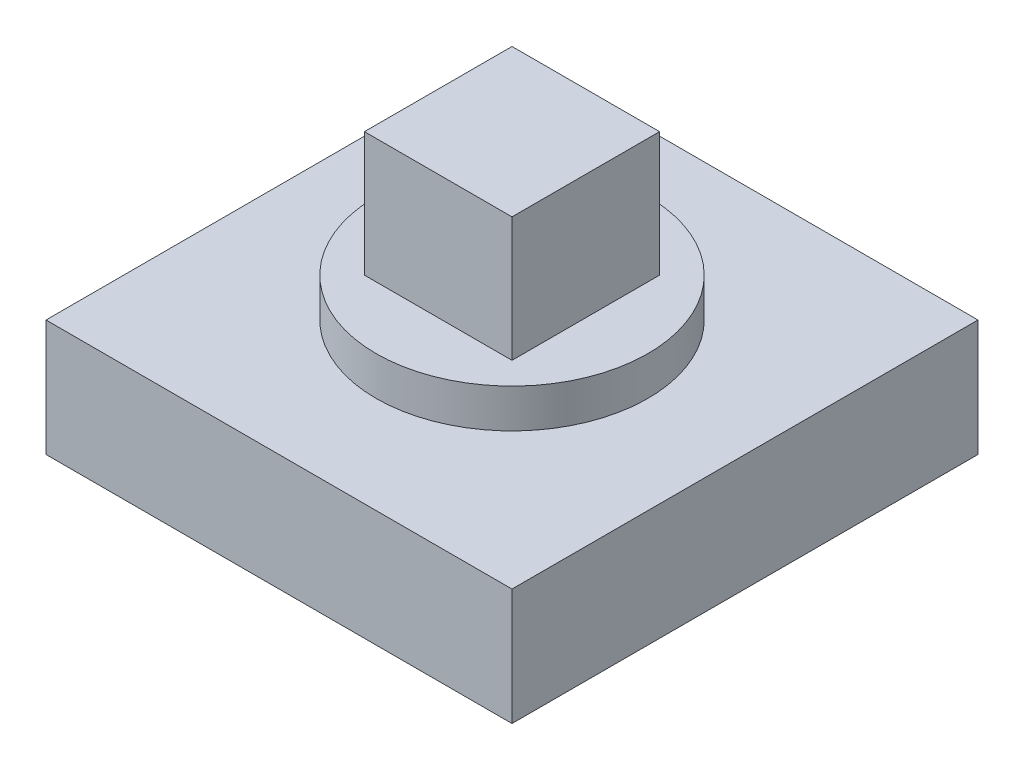
from build123d import *

# Parameters (mm, degrees)
SKETCH1_W           = 12
SKETCH1_H           = 12
BOSS_EXTRUDE1_DEPTH = 3
SKETCH3_R           = 3.5
BOSS_EXTRUDE2_DEPTH = 1
SKETCH4_W           = 3.8
SKETCH4_H           = 3.8
BOSS_EXTRUDE3_DEPTH = 3.2


with BuildPart() as part:
    # Sketch1 → Boss-Extrude1 (new body)
    with BuildSketch(Plane(origin=(0, 0, 0), x_dir=(1, 0, 0), z_dir=(0, 1, 0))):
        Rectangle(SKETCH1_W, SKETCH1_H)
    extrude(amount=BOSS_EXTRUDE1_DEPTH)

    # Sketch3 → Boss-Extrude2 (add)
    with BuildSketch(Plane(origin=(0, 3, 0), x_dir=(1, 0, 0), z_dir=(0, 1, 0))):
        Circle(SKETCH3_R)
    extrude(amount=BOSS_EXTRUDE2_DEPTH)

    # Sketch4 → Boss-Extrude3 (add)
    with BuildSketch(Plane(origin=(0, 4, 0), x_dir=(1, 0, 0), z_dir=(0, 1, 0))):
        Rectangle(SKETCH4_W, SKETCH4_H)
    extrude(amount=BOSS_EXTRUDE3_DEPTH)


solid = part.part
